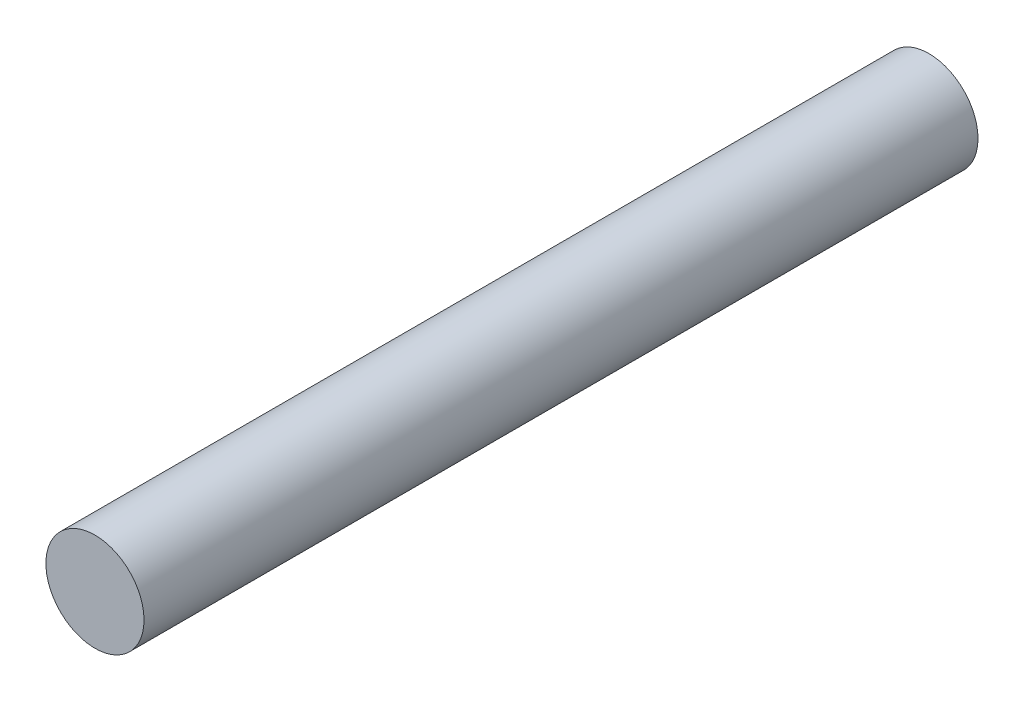
from build123d import *

# Parameters (mm, degrees)
ESQUISSE1_R        = 5
BOSS_EXTRU_1_DEPTH = 85


with BuildPart() as part:
    # Esquisse1 → Boss.-Extru.1 (new body)
    with BuildSketch(Plane.XY):
        Circle(ESQUISSE1_R)
    extrude(amount=BOSS_EXTRU_1_DEPTH)


solid = part.part
